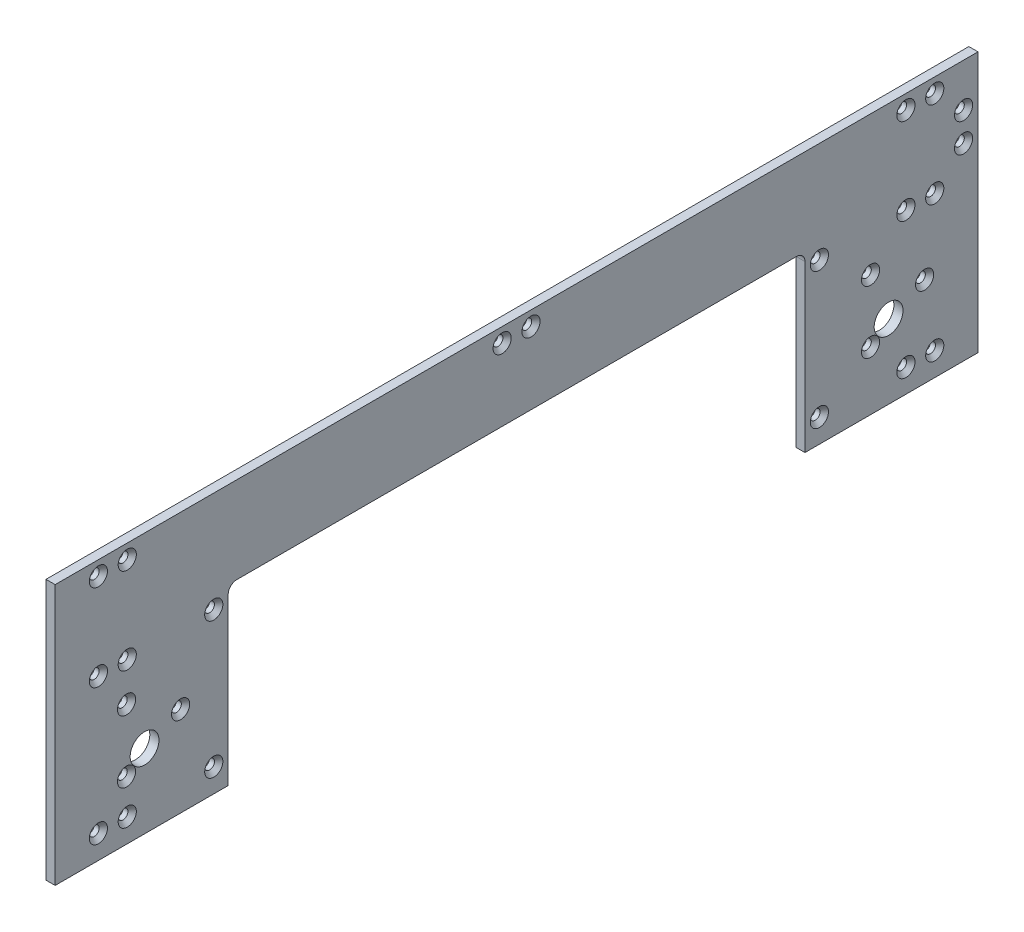
from build123d import *

# Parameters (mm, degrees)
BOSS_EXTRUDE1_DEPTH                             = 3.175
CSK_FOR_M3_FLAT_HEAD_MACHINE_SCREW1_D           = 3.4
CSK_FOR_M3_FLAT_HEAD_MACHINE_SCREW1_CSINK_D     = 6.3
CSK_FOR_M3_FLAT_HEAD_MACHINE_SCREW1_CSINK_ANGLE = 90
SKETCH4_R                                       = 5
CUT_EXTRUDE1_DEPTH                              = 4.175
CSK_FOR_M3_FLAT_HEAD_MACHINE_SCREW2_D           = 3.4
CSK_FOR_M3_FLAT_HEAD_MACHINE_SCREW2_CSINK_D     = 6.3
CSK_FOR_M3_FLAT_HEAD_MACHINE_SCREW2_CSINK_ANGLE = 90
CSK_FOR_M3_FLAT_HEAD_MACHINE_SCREW3_D           = 3.4
CSK_FOR_M3_FLAT_HEAD_MACHINE_SCREW3_CSINK_D     = 6.3
CSK_FOR_M3_FLAT_HEAD_MACHINE_SCREW3_CSINK_ANGLE = 90
LPATTERN1_COUNT                                 = 2
LPATTERN1_PITCH                                 = 258


with BuildPart() as part:
    # Sketch1 → Boss-Extrude1 (new body)
    with BuildSketch(Plane(origin=(0, 0, 0), x_dir=(0, 0, -1), z_dir=(1, 0, 0))):
        Polygon((160, 0), (160, 3.175), (160, 47.175), (160, 50.35), (160, 60.35), (160, 90.35), (-160, 90.35), (-160, 60.35), (-160, 50.35), (-160, 47.175), (-160, 3.175), (-160, 0), align=None)
    extrude(amount=BOSS_EXTRUDE1_DEPTH)

    # CSK for M3 Flat Head Machine Screw1 (through all)
    with Locations(Plane(origin=(3.175, 0, 0), x_dir=(0, 0, -1), z_dir=(1, 0, 0))):
        with Locations((-145, 8.175), (-135, 8.175), (-105, 8.175), (-145, 55.35), (-135, 55.35), (-105, 55.35), (-145, 85.35), (-135, 85.35), (-5, 85.35)):
            csk_for_m3_flat_head_machine_screw1 = CounterSinkHole(CSK_FOR_M3_FLAT_HEAD_MACHINE_SCREW1_D / 2, CSK_FOR_M3_FLAT_HEAD_MACHINE_SCREW1_CSINK_D / 2, counter_sink_angle=CSK_FOR_M3_FLAT_HEAD_MACHINE_SCREW1_CSINK_ANGLE)

    # Mirror1: CSK for M3 Flat Head Machine Screw1 across plane
    add(csk_for_m3_flat_head_machine_screw1.mirror(Plane.XY), mode=Mode.SUBTRACT)

    # Sketch4 → Cut-Extrude1 (cut, through all)
    with BuildSketch(Plane(origin=(3.175, 0, 0), x_dir=(0, 0, -1), z_dir=(1, 0, 0))):
        with Locations((-129, 25.675)):
            Circle(SKETCH4_R)
        with Locations((129, 25.675)):
            Circle(SKETCH4_R)
        with BuildLine():
            Line((-100, 57.35), (-100, 0))
            Line((-100, 0), (100, 0))
            Line((100, 0), (100, 57.35))
            ThreePointArc((100, 57.35), (99.121320344, 59.471320344), (97, 60.35))
            Line((97, 60.35), (-97, 60.35))
            ThreePointArc((-97, 60.35), (-99.121320344, 59.471320344), (-100, 57.35))
        make_face()
    extrude(amount=-CUT_EXTRUDE1_DEPTH, mode=Mode.SUBTRACT)

    # CSK for M3 Flat Head Machine Screw2 (through all)
    with Locations(Plane(origin=(3.175, 0, 0), x_dir=(0, 0, -1), z_dir=(1, 0, 0))):
        with Locations((155, 65.35), (155, 75.35)):
            CounterSinkHole(CSK_FOR_M3_FLAT_HEAD_MACHINE_SCREW2_D / 2, CSK_FOR_M3_FLAT_HEAD_MACHINE_SCREW2_CSINK_D / 2, counter_sink_angle=CSK_FOR_M3_FLAT_HEAD_MACHINE_SCREW2_CSINK_ANGLE)

    # CSK for M3 Flat Head Machine Screw3 (through all)
    with Locations(Plane(origin=(3.175, 0, 0), x_dir=(0, 0, -1), z_dir=(1, 0, 0))):
        with Locations((-116.5, 31.175), (-135.25, 20.349682453), (-135.25, 42.000317547)):
            csk_for_m3_flat_head_machine_screw3 = CounterSinkHole(CSK_FOR_M3_FLAT_HEAD_MACHINE_SCREW3_D / 2, CSK_FOR_M3_FLAT_HEAD_MACHINE_SCREW3_CSINK_D / 2, counter_sink_angle=CSK_FOR_M3_FLAT_HEAD_MACHINE_SCREW3_CSINK_ANGLE)

    # LPattern1: CSK for M3 Flat Head Machine Screw3 ×2
    with Locations(*[(0, 0, -i * LPATTERN1_PITCH) for i in range(1, LPATTERN1_COUNT)]):
        add(csk_for_m3_flat_head_machine_screw3, mode=Mode.SUBTRACT)


solid = part.part
